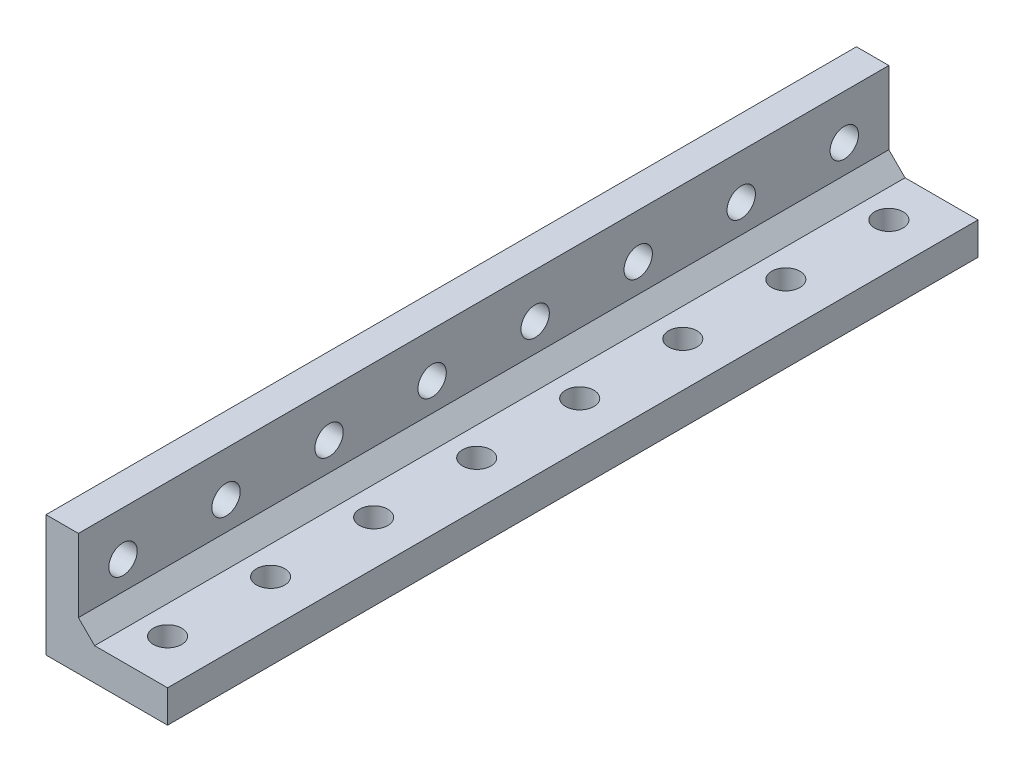
from build123d import *

# Parameters (mm, degrees)
RESSALTO_EXTRUS_O1_DEPTH = 100
ESBO_O2_R                = 1.75
CORTE_EXTRUS_O1_DEPTH    = 100
PADR_O_LINEAR1_COUNT     = 8
PADR_O_LINEAR1_PITCH     = 12.714285714
ESBO_O3_R                = 1.75
CORTE_EXTRUS_O2_DEPTH    = 100
PADR_O_LINEAR2_COUNT     = 8
PADR_O_LINEAR2_PITCH     = 12.714285714
CHANFRO1_SIZE            = 2


with BuildPart() as part:
    # Esboço1 → Ressalto-extrusão1 (new body)
    with BuildSketch(Plane.XY):
        Polygon((0, 0), (0, 15), (4, 15), (4, 4), (15, 4), (15, 0), align=None)
    extrude(amount=RESSALTO_EXTRUS_O1_DEPTH)

    # Esboço2 → Corte-extrusão1 (cut)
    with BuildSketch(Plane(origin=(4, 0, 0), x_dir=(0, 0, -1), z_dir=(1, 0, 0))):
        with Locations((-94.5, 9.5)):
            Circle(ESBO_O2_R)
    corte_extrus_o1 = extrude(amount=-CORTE_EXTRUS_O1_DEPTH, mode=Mode.SUBTRACT)

    # Padrão linear1: Corte-extrusão1 ×8
    with Locations(*[(0, 0, -i * PADR_O_LINEAR1_PITCH) for i in range(1, PADR_O_LINEAR1_COUNT)]):
        add(corte_extrus_o1, mode=Mode.SUBTRACT)

    # Esboço3 → Corte-extrusão2 (cut)
    with BuildSketch(Plane(origin=(0, 4, 0), x_dir=(1, 0, 0), z_dir=(0, 1, 0))):
        with Locations((9.5, -94.5)):
            Circle(ESBO_O3_R)
    corte_extrus_o2 = extrude(amount=-CORTE_EXTRUS_O2_DEPTH, mode=Mode.SUBTRACT)

    # Padrão linear2: Corte-extrusão2 ×8
    with Locations(*[(0, 0, -i * PADR_O_LINEAR2_PITCH) for i in range(1, PADR_O_LINEAR2_COUNT)]):
        add(corte_extrus_o2, mode=Mode.SUBTRACT)

    # Chanfro1
    chanfro1_edges = [part.edges().sort_by_distance(p)[0] for p in [
        (4, 4, 50),
    ]]
    chamfer(chanfro1_edges, length=CHANFRO1_SIZE)


solid = part.part
